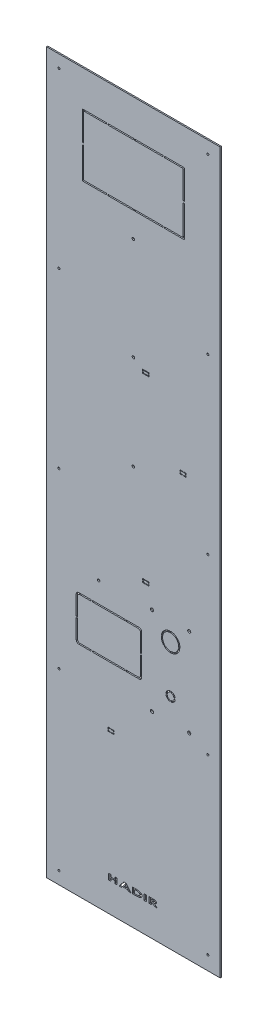
from build123d import *

# Parameters (mm, degrees)
BOSS_EXTRUDE2_DEPTH = 2
SKETCH3_R           = 2
SKETCH3_R_2         = 1.65
SKETCH3_R_3         = 2.5
SKETCH3_W           = 41.109833897
SKETCH3_H           = 2
SKETCH3_W_2         = 46.02015594
SKETCH3_W_3         = 52.483601223
CUT_EXTRUDE8_DEPTH  = 2
SKETCH4_W           = 3.627685547
SKETCH4_H           = 9.431982422
CUT_EXTRUDE9_DEPTH  = 2


with BuildPart() as part:
    # Sketch2 → Boss-Extrude2 (new body)
    with BuildSketch(Plane.XY):
        Polygon((-140, 680), (140, 680), (140, 580), (140, -480), (-140, -480), align=None)
    extrude(amount=BOSS_EXTRUDE2_DEPTH)

    # Sketch3 → Cut-Extrude8 (cut)
    with BuildSketch(Plane.XY):
        with Locations((-56.100012279, -23)):
            Circle(SKETCH3_R)
        with Locations((-120, -460)):
            Circle(SKETCH3_R_2)
        with Locations((120, -457.6)):
            Circle(SKETCH3_R_2)
        with Locations((90, -21)):
            Circle(SKETCH3_R_3)
        with Locations((89.999987721, -163)):
            Circle(SKETCH3_R_3)
        with Locations((29.999987721, -163)):
            Circle(SKETCH3_R_3)
        with Locations((29.999987721, -21)):
            Circle(SKETCH3_R_3)
        with Locations((-120, 660)):
            Circle(SKETCH3_R_2)
        with Locations((120, 660)):
            Circle(SKETCH3_R_2)
        with Locations((-120, 380.6)):
            Circle(SKETCH3_R_2)
        with Locations((120, 380.6)):
            Circle(SKETCH3_R_2)
        with Locations((120, -178.2)):
            Circle(SKETCH3_R_2)
        with Locations((-120, -178.2)):
            Circle(SKETCH3_R_2)
        with Locations((120, 101.2)):
            Circle(SKETCH3_R_2)
        with Locations((-120, 101.2)):
            Circle(SKETCH3_R_2)
        with Locations((0, 481.600002813)):
            Circle(SKETCH3_R)
        with Locations((0, 316.500002813)):
            Circle(SKETCH3_R)
        with Locations((0, 164.100002813)):
            Circle(SKETCH3_R)
        with BuildLine():
            Line((60, -36), (60.00001461, -38.000005513))
            ThreePointArc((60.00001461, -38.000005513), (64.40229458, -38.768082792), (68.284375962, -40.981554223))
            Line((68.284375962, -40.981554223), (69.558885127, -39.44026342))
            ThreePointArc((69.558885127, -39.44026342), (65.079558828, -36.88624879), (60, -36))
        make_face()
        with BuildLine():
            Line((59.000556004, -36.033342163), (59.122400034, -38.029662698))
            ThreePointArc((59.122400034, -38.029662698), (54.411111276, -39.262707552), (50.484141952, -42.142907772))
            Line((50.484141952, -42.142907772), (49.02015594, -40.780271897))
            ThreePointArc((49.02015594, -40.780271897), (53.557238864, -37.45413019), (59.000556004, -36.033342163))
        make_face()
        with BuildLine():
            Line((74.933661101, -52.409179713), (72.94252229, -52.221291353))
            ThreePointArc((72.94252229, -52.221291353), (72.168738974, -46.425929265), (68.933492433, -41.555801733))
            Line((68.933492433, -41.555801733), (70.307864595, -40.102856625))
            ThreePointArc((70.307864595, -40.102856625), (74.040835155, -45.722230337), (74.933661101, -52.409179713))
        make_face()
        with BuildLine():
            Line((74.806582661, -53.401072383), (72.832387322, -53.080932568))
            ThreePointArc((72.832387322, -53.080932568), (71.39953375, -57.249087296), (68.656303527, -60.698909196))
            Line((68.656303527, -60.698909196), (69.988033372, -62.191040241))
            ThreePointArc((69.988033372, -62.191040241), (73.153293496, -58.210477998), (74.806582661, -53.401072383))
        make_face()
        with BuildLine():
            Line((60, -66.000017478), (60.00001461, -64.000008617))
            ThreePointArc((60.00001461, -64.000008617), (64.224735631, -63.294386783), (67.990832799, -61.254121606))
            Line((67.990832799, -61.254121606), (69.220183567, -62.831670149))
            ThreePointArc((69.220183567, -62.831670149), (64.874684241, -65.185832318), (60, -66.000017478))
        make_face()
        with BuildLine():
            Line((59.000541044, -65.96712681), (59.000541044, -63.961530623))
            ThreePointArc((59.000541044, -63.961530623), (54.566773379, -62.810169218), (50.807625358, -60.192396318))
            Line((50.807625358, -60.192396318), (49.393414477, -61.606607198))
            ThreePointArc((49.393414477, -61.606607198), (53.800950165, -64.659397705), (59.000541044, -65.96712681))
        make_face()
        with BuildLine():
            Line((60.980600924, -119.564383163), (60.71910407, -121.54721432))
            ThreePointArc((60.71910407, -121.54721432), (63.889075017, -123.110912704), (65.452773401, -126.280883651))
            Line((65.452773401, -126.280883651), (67.435604557, -126.019386797))
            ThreePointArc((67.435604557, -126.019386797), (65.30328858, -121.696699141), (60.980600924, -119.564383163))
        make_face()
        with BuildLine():
            Line((58.987382691, -119.568672322), (59.257410699, -121.550359703))
            ThreePointArc((59.257410699, -121.550359703), (56.102540613, -123.119290524), (54.54720204, -126.280883651))
            Line((54.54720204, -126.280883651), (52.564370884, -126.019386797))
            ThreePointArc((52.564370884, -126.019386797), (54.685287119, -121.708123441), (58.987382691, -119.568672322))
        make_face()
        with BuildLine():
            Line((67.435604557, -127.980613203), (65.452773401, -127.719116349))
            ThreePointArc((65.452773401, -127.719116349), (63.889075017, -130.889087296), (60.71910407, -132.45278568))
            Line((60.71910407, -132.45278568), (60.980600924, -134.435616836))
            ThreePointArc((60.980600924, -134.435616836), (65.303288579, -132.303300859), (67.435604557, -127.980613203))
        make_face()
        with BuildLine():
            Line((52.564370884, -127.980613203), (54.54720204, -127.719116349))
            ThreePointArc((54.54720204, -127.719116349), (56.102540613, -130.880709476), (59.257410699, -132.449640297))
            Line((59.257410699, -132.449640297), (58.987382691, -134.431327677))
            ThreePointArc((58.987382691, -134.431327677), (54.685287119, -132.291876559), (52.564370884, -127.980613203))
        make_face()
        with BuildLine():
            Line((45.263274159, -48.201990118), (47.228183224, -48.575061007))
            ThreePointArc((47.228183224, -48.575061007), (48.212106329, -45.518651513), (49.915143539, -42.796628748))
            Line((49.915143539, -42.796628748), (48.363618413, -41.534565259))
            ThreePointArc((48.363618413, -41.534565259), (46.398572229, -44.675361768), (45.263274159, -48.201990118))
        make_face()
        with BuildLine():
            Line((45.108152373, -49.201990118), (47.093744677, -49.441726999))
            ThreePointArc((47.093744677, -49.441726999), (47.511194531, -54.609634938), (49.915144959, -59.203387129))
            Line((49.915144959, -59.203387129), (48.363618413, -60.46545222))
            ThreePointArc((48.363618413, -60.46545222), (45.589825437, -55.164965615), (45.108152373, -49.201990118))
        make_face()
        Polygon((-32.100012279, -221.1), (-35.600012279, -221.1), (-35.600012279, -220.1), (-31.100012279, -220.1), (-31.100012279, -222.5), (-32.100012279, -222.5), align=None)
        with BuildLine():
            Line((13.479987721, -60), (13.479987721, -91))
            Line((13.479987721, -91), (11.479987721, -91))
            Line((11.479987721, -91), (11.479987721, -62))
            ThreePointArc((11.479987721, -62), (10.308414845, -59.171572875), (7.479987721, -58))
            Line((7.479987721, -58), (-11.516442734, -58))
            Line((-11.516442734, -58), (-11.516442734, -56))
            Line((-11.516442734, -56), (9.479987721, -56))
            ThreePointArc((9.479987721, -56), (12.308414845, -57.171572875), (13.479987721, -60))
        make_face()
        with BuildLine():
            Line((9.479987721, -128), (-11.516442734, -128))
            Line((-11.516442734, -128), (-11.516442734, -126))
            Line((-11.516442734, -126), (7.479987721, -126))
            ThreePointArc((7.479987721, -126), (10.308414845, -124.828427125), (11.479987721, -122))
            Line((11.479987721, -122), (11.479987721, -93))
            Line((11.479987721, -93), (13.479987721, -93))
            Line((13.479987721, -93), (13.479987721, -124))
            ThreePointArc((13.479987721, -124), (12.308414845, -126.828427125), (9.479987721, -128))
        make_face()
        Polygon((24, 14.300002813), (24, 12.900002813), (25, 12.900002813), (25, 15.300002813), (20.5, 15.300002813), (20.5, 14.300002813), align=None)
        Polygon((-40.100012279, -221.1), (-40.100012279, -222.5), (-41.100012279, -222.5), (-41.100012279, -220.1), (-36.600012279, -220.1), (-36.600012279, -221.1), align=None)
        Polygon((24, 306.400002813), (24, 305.000002813), (25, 305.000002813), (25, 307.400002813), (20.5, 307.400002813), (20.5, 306.400002813), align=None)
        Polygon((84, 196.000002813), (84, 194.600002813), (85, 194.600002813), (85, 197.000002813), (80.5, 197.000002813), (80.5, 196.000002813), align=None)
        Polygon((-31.100012279, -225.9), (-35.600012279, -225.9), (-35.600012279, -224.9), (-32.100012279, -224.9), (-32.100012279, -223.5), (-31.100012279, -223.5), align=None)
        Polygon((25, 9.500002813), (20.5, 9.500002813), (20.5, 10.500002813), (24, 10.500002813), (24, 11.900002813), (25, 11.900002813), align=None)
        Polygon((15, 15.300002813), (15, 12.900002813), (16, 12.900002813), (16, 14.300002813), (19.5, 14.300002813), (19.5, 15.300002813), align=None)
        Polygon((19.5, 10.500002813), (16, 10.500002813), (16, 11.900002813), (15, 11.900002813), (15, 9.500002813), (19.5, 9.500002813), align=None)
        Polygon((-40.100012279, -223.5), (-40.100012279, -224.9), (-36.600012279, -224.9), (-36.600012279, -225.9), (-41.100012279, -225.9), (-41.100012279, -223.5), align=None)
        with BuildLine():
            Line((81.2, 622.2), (50.00515594, 622.2))
            Line((50.00515594, 622.2), (50.00515594, 620.2))
            Line((50.00515594, 620.2), (79.2, 620.2))
            ThreePointArc((79.2, 620.2), (79.907106781, 619.907106781), (80.2, 619.2))
            Line((80.2, 619.2), (80.2, 575.26))
            Line((80.2, 575.26), (82.2, 575.26))
            Line((82.2, 575.26), (82.2, 621.2))
            ThreePointArc((82.2, 621.2), (81.907106781, 621.907106781), (81.2, 622.2))
        make_face()
        with BuildLine():
            Line((81.2, 521.6), (50.00515594, 521.6))
            Line((50.00515594, 521.6), (50.00515594, 523.6))
            Line((50.00515594, 523.6), (79.2, 523.6))
            ThreePointArc((79.2, 523.6), (79.907106781, 523.892893219), (80.2, 524.6))
            Line((80.2, 524.6), (80.2, 572.28))
            Line((80.2, 572.28), (82.2, 572.28))
            Line((82.2, 572.28), (82.2, 522.6))
            ThreePointArc((82.2, 522.6), (81.907106781, 521.892893219), (81.2, 521.6))
        make_face()
        with BuildLine():
            Line((-82.2, 522.6), (-82.2, 572.28))
            Line((-82.2, 572.28), (-80.2, 572.28))
            Line((-80.2, 572.28), (-80.2, 524.6))
            ThreePointArc((-80.2, 524.6), (-79.907106781, 523.892893219), (-79.2, 523.6))
            Line((-79.2, 523.6), (-43.124833897, 523.6))
            Line((-43.124833897, 523.6), (-43.124833897, 521.6))
            Line((-43.124833897, 521.6), (-81.2, 521.6))
            ThreePointArc((-81.2, 521.6), (-81.907106781, 521.892893219), (-82.2, 522.6))
        make_face()
        with Locations((-20.569916949, 522.6)):
            Rectangle(SKETCH3_W, SKETCH3_H)
        with Locations((24.99507797, 621.2)):
            Rectangle(SKETCH3_W_2, SKETCH3_H)
        with Locations((-20.569916949, 621.2)):
            Rectangle(SKETCH3_W, SKETCH3_H)
        with Locations((24.99507797, 522.6)):
            Rectangle(SKETCH3_W_2, SKETCH3_H)
        with BuildLine():
            Line((-43.124833897, 622.2), (-43.124833897, 620.2))
            Line((-43.124833897, 620.2), (-79.2, 620.2))
            ThreePointArc((-79.2, 620.2), (-79.907106781, 619.907106781), (-80.2, 619.2))
            Line((-80.2, 619.2), (-80.2, 575.26))
            Line((-80.2, 575.26), (-82.2, 575.26))
            Line((-82.2, 575.26), (-82.2, 621.2))
            ThreePointArc((-82.2, 621.2), (-81.907106781, 621.907106781), (-81.2, 622.2))
            Line((-81.2, 622.2), (-43.124833897, 622.2))
        make_face()
        with BuildLine():
            Line((-92.120012279, -124), (-92.120012279, -93))
            Line((-92.120012279, -93), (-90.120012279, -93))
            Line((-90.120012279, -93), (-90.120012279, -122))
            ThreePointArc((-90.120012279, -122), (-88.948439404, -124.828427125), (-86.120012279, -126))
            Line((-86.120012279, -126), (-68.000043957, -126))
            Line((-68.000043957, -126), (-68.000043957, -128))
            Line((-68.000043957, -128), (-88.120012279, -128))
            ThreePointArc((-88.120012279, -128), (-90.948439404, -126.828427125), (-92.120012279, -124))
        make_face()
        with BuildLine():
            Line((-88.120012279, -56), (-68.000043957, -56))
            Line((-68.000043957, -56), (-68.000043957, -58))
            Line((-68.000043957, -58), (-86.120012279, -58))
            ThreePointArc((-86.120012279, -58), (-88.948439404, -59.171572875), (-90.120012279, -62))
            Line((-90.120012279, -62), (-90.120012279, -91))
            Line((-90.120012279, -91), (-92.120012279, -91))
            Line((-92.120012279, -91), (-92.120012279, -60))
            ThreePointArc((-92.120012279, -60), (-90.948439404, -57.171572875), (-88.120012279, -56))
        make_face()
        with Locations((-39.758243345, -57)):
            Rectangle(SKETCH3_W_3, SKETCH3_H)
        with Locations((-39.758243345, -127)):
            Rectangle(SKETCH3_W_3, SKETCH3_H)
        Polygon((25, 301.600002813), (20.5, 301.600002813), (20.5, 302.600002813), (24, 302.600002813), (24, 304.000002813), (25, 304.000002813), align=None)
        Polygon((15, 307.400002813), (15, 305.000002813), (16, 305.000002813), (16, 306.400002813), (19.5, 306.400002813), (19.5, 307.400002813), align=None)
        Polygon((85, 191.200002813), (80.5, 191.200002813), (80.5, 192.200002813), (84, 192.200002813), (84, 193.600002813), (85, 193.600002813), align=None)
        Polygon((75, 197.000002813), (75, 194.600002813), (76, 194.600002813), (76, 196.000002813), (79.5, 196.000002813), (79.5, 197.000002813), align=None)
        Polygon((19.5, 302.600002813), (16, 302.600002813), (16, 304.000002813), (15, 304.000002813), (15, 301.600002813), (19.5, 301.600002813), align=None)
        Polygon((79.5, 192.200002813), (76, 192.200002813), (76, 193.600002813), (75, 193.600002813), (75, 191.200002813), (79.5, 191.200002813), align=None)
    extrude(amount=CUT_EXTRUDE8_DEPTH, mode=Mode.SUBTRACT)

    # Sketch4 → Cut-Extrude9 (cut)
    with BuildSketch(Plane.XY):
        Polygon((-40.061027035, -423.68864967), (-36.433341488, -423.68864967), (-36.433341488, -427.316335217), (-29.6616618, -427.316335217), (-29.6616618, -423.68864967), (-26.033976253, -423.68864967), (-26.033976253, -433.120632092), (-29.6616618, -433.120632092), (-29.6616618, -429.009255138), (-36.433341488, -429.009255138), (-36.433341488, -433.120632092), (-40.061027035, -433.120632092), align=None)
        Polygon((-15.491015133, -423.68864967), (-11.785863384, -423.68864967), (-4.207401546, -433.120632092), (-8.093937572, -433.120632092), (-9.611141476, -431.185866467), (-17.667626461, -431.185866467), (-19.186719784, -433.120632092), (-23.07136639, -433.120632092), align=None)
        Polygon((-13.639383968, -426.218582455), (-16.339364513, -429.492946545), (-10.939403423, -429.492946545), align=None, mode=Mode.SUBTRACT)
        with BuildLine():
            Line((-1.486637386, -423.68864967), (2.95160915, -423.68864967))
            add(Edge.make_bspline(
                [(2.95160915, -423.68864967), (3.127327275, -423.688984823), (3.473734374, -423.689645537), (3.984515834, -423.695685686), (4.478350403, -423.704067328), (4.953790876, -423.720625979), (5.412412885, -423.736176275), (5.853899353, -423.759315101), (6.278321351, -423.786325767), (6.685408819, -423.813231538), (7.075154297, -423.848339144), (7.448276564, -423.884635264), (7.80385513, -423.929478174), (8.141659663, -423.9739191), (8.462517036, -424.022529563), (8.765710611, -424.078458407), (9.053004398, -424.133230716), (9.408853454, -424.217203151), (9.832496402, -424.331407802), (10.320683059, -424.487008028), (10.784783877, -424.666108186), (11.227457581, -424.861052742), (11.646240214, -425.079226502), (12.041481068, -425.316854837), (12.41295266, -425.57550624), (12.761699089, -425.848567784), (13.078282801, -426.138685314), (13.354690295, -426.444469014), (13.588707038, -426.762363789), (13.779621562, -427.093773412), (13.928074195, -427.437460575), (14.033953451, -427.793165455), (14.101374841, -428.160870938), (14.108705223, -428.410647325), (14.112410465, -428.536900249)],
                knots=[0, 0, 0, 0, 0.000527151, 0.001039216, 0.001532444, 0.002008818, 0.002466374, 0.002909079, 0.00333502, 0.003742233, 0.004132937, 0.004508945, 0.004866805, 0.005208037, 0.005531106, 0.005840198, 0.00613293, 0.006408377, 0.006936837, 0.007448912, 0.007944721, 0.008428546, 0.008899258, 0.009360357, 0.009811102, 0.010256384, 0.010688268, 0.011097649, 0.011491052, 0.011870238, 0.012242626, 0.01261145, 0.012981723, 0.013360179, 0.013360179, 0.013360179, 0.013360179], degree=3))
            add(Edge.make_bspline(
                [(14.112410465, -428.536900249), (14.110484441, -428.627098675), (14.106670519, -428.805709991), (14.068368459, -429.070447547), (14.01094765, -429.330126093), (13.926475466, -429.583856009), (13.820895386, -429.832895641), (13.688582279, -430.075084434), (13.536383202, -430.313918356), (13.357640248, -430.543805465), (13.158773745, -430.765946054), (12.944145359, -430.981660126), (12.710273523, -431.18637538), (12.458359384, -431.381074155), (12.188485584, -431.566142684), (11.899297101, -431.739806402), (11.594237531, -431.906411793), (11.160697439, -432.112544177), (10.593854146, -432.343941389), (9.88567113, -432.57700142), (9.149332163, -432.761814491), (8.579370263, -432.864239729), (8.18305888, -432.919922558), (7.962672228, -432.946711485), (7.723694997, -432.968078666), (7.467474215, -432.991456007), (7.193458078, -433.011899786), (6.902471813, -433.030730287), (6.593858222, -433.047893384), (6.266914688, -433.062122184), (5.92187515, -433.078518856), (5.559031842, -433.088808208), (5.178635285, -433.098718654), (4.780563246, -433.105247047), (4.364929275, -433.114380819), (3.931583196, -433.116357075), (3.480657457, -433.121767599), (3.173932727, -433.121015225), (3.017738834, -433.120632092)],
                knots=[0, 0, 0, 0, 0.000270425, 0.000535496, 0.000800891, 0.001067373, 0.001336554, 0.0016113, 0.001894316, 0.002185311, 0.00248375, 0.002788363, 0.003097633, 0.003415472, 0.003743018, 0.004078718, 0.004427049, 0.004785366, 0.00551833, 0.006262207, 0.007020156, 0.007793984, 0.007998128, 0.008220768, 0.008459912, 0.008717871, 0.008992624, 0.009284207, 0.009592652, 0.009919871, 0.010265965, 0.010628911, 0.011008801, 0.01140754, 0.011823281, 0.012255975, 0.012707562, 0.013176138, 0.013176138, 0.013176138, 0.013176138], degree=3))
            Line((3.017738834, -433.120632092), (-1.486637386, -433.120632092))
            Line((-1.486637386, -433.120632092), (-1.486637386, -423.68864967))
        make_face()
        with BuildLine():
            Line((2.141048161, -425.381569592), (2.141048161, -431.42771217))
            Line((2.141048161, -431.42771217), (3.934107319, -431.42771217))
            add(Edge.make_bspline(
                [(3.934107319, -431.42771217), (4.146998468, -431.427503063), (4.55772495, -431.427099638), (5.150970696, -431.409565982), (5.699832088, -431.391723109), (6.202391293, -431.358279757), (6.660193029, -431.321072779), (7.071211746, -431.268296371), (7.438911053, -431.21488409), (7.765171715, -431.145052283), (8.062884447, -431.066400653), (8.341503841, -430.975771473), (8.607161326, -430.874589528), (8.857394385, -430.757810165), (9.09532529, -430.632351579), (9.319648148, -430.493792486), (9.529971516, -430.342329842), (9.725290704, -430.179016328), (9.90432306, -430.005892076), (10.059146754, -429.820748384), (10.191202686, -429.626014684), (10.300213506, -429.422067721), (10.380436068, -429.205919391), (10.442319526, -428.981868164), (10.478664669, -428.747184883), (10.482690582, -428.587406984), (10.484724918, -428.506669537)],
                knots=[0, 0, 0, 0, 0.000638635, 0.001232105, 0.001780431, 0.002285927, 0.002743003, 0.003158044, 0.003528948, 0.003857272, 0.004158378, 0.004452352, 0.004735865, 0.005010612, 0.005280243, 0.00554241, 0.005800929, 0.006057118, 0.006305633, 0.006547065, 0.00677974, 0.007010473, 0.007238913, 0.007469918, 0.00770694, 0.007949051, 0.007949051, 0.007949051, 0.007949051], degree=3))
            add(Edge.make_bspline(
                [(10.484724918, -428.506669537), (10.483162085, -428.4436347), (10.480090322, -428.319739135), (10.459032776, -428.136374978), (10.422989635, -427.958929616), (10.373280771, -427.786008048), (10.312002089, -427.617758209), (10.233094203, -427.455735831), (10.140412821, -427.299355736), (10.034967394, -427.147814744), (9.913482642, -427.003199871), (9.780789134, -426.861287444), (9.630334181, -426.727652105), (9.466985972, -426.599174986), (9.291235272, -426.473642042), (9.100058307, -426.355540875), (8.895597455, -426.241093396), (8.751905731, -426.17243877), (8.678439823, -426.137337414)],
                knots=[0, 0, 0, 0, 0.000189093, 0.000371664, 0.000552861, 0.000731679, 0.000911024, 0.001089332, 0.001271443, 0.001455949, 0.001642467, 0.001837599, 0.002038287, 0.002245435, 0.002460903, 0.002685816, 0.002919249, 0.003163452, 0.003163452, 0.003163452, 0.003163452], degree=3))
            add(Edge.make_bspline(
                [(8.678439823, -426.137337414), (8.608120409, -426.10658828), (8.4636369, -426.043408817), (8.237146977, -425.956333197), (7.994603018, -425.877699001), (7.737475128, -425.804000384), (7.464583061, -425.736101773), (7.17673991, -425.673650497), (6.872627983, -425.620014631), (6.554241401, -425.567708302), (6.219307042, -425.526126542), (5.869387448, -425.484831668), (5.503816969, -425.4540879), (5.122765179, -425.427224308), (4.726537323, -425.406933574), (4.314625679, -425.391145077), (3.88752041, -425.384727301), (3.597791205, -425.382634253), (3.450415913, -425.381569592)],
                knots=[0, 0, 0, 0, 0.00023023, 0.000473048, 0.00072758, 0.000994898, 0.001275348, 0.001571077, 0.00187831, 0.002201671, 0.00253891, 0.002890697, 0.003258649, 0.003639343, 0.004036665, 0.004448836, 0.004875911, 0.005318052, 0.005318052, 0.005318052, 0.005318052], degree=3))
            Line((3.450415913, -425.381569592), (2.141048161, -425.381569592))
        make_face(mode=Mode.SUBTRACT)
        with Locations((18.949324528, -428.404640881)):
            Rectangle(SKETCH4_W, SKETCH4_H)
        with BuildLine():
            Line((25.479158512, -423.68864967), (29.465833775, -423.68864967))
            add(Edge.make_bspline(
                [(29.465833775, -423.68864967), (29.599981747, -423.689364143), (29.863239385, -423.690766256), (30.250595035, -423.691389972), (30.622806042, -423.697815745), (30.980548006, -423.705089853), (31.323160558, -423.714743859), (31.651372201, -423.725102256), (31.96489456, -423.741771258), (32.264223846, -423.755147652), (32.548204916, -423.774875546), (32.817157845, -423.795469182), (33.071632762, -423.818007273), (33.311625483, -423.842445631), (33.537122555, -423.868927877), (33.747541168, -423.896995872), (33.943672138, -423.926699181), (34.181933284, -423.972240094), (34.463783083, -424.032958731), (34.786177735, -424.117297658), (35.091373182, -424.213832883), (35.379166008, -424.32123663), (35.650251427, -424.440804676), (35.905270256, -424.57006067), (36.142402321, -424.712499419), (36.361349169, -424.864655794), (36.5588835, -425.025902521), (36.73349202, -425.194347525), (36.878992173, -425.372516519), (36.999968932, -425.556896556), (37.093615603, -425.749241346), (37.159722433, -425.948734603), (37.201464863, -426.155760237), (37.206248882, -426.296480053), (37.208675114, -426.3678466)],
                knots=[0, 0, 0, 0, 0.000402451, 0.000789786, 0.001162045, 0.001519225, 0.00186323, 0.002190296, 0.002504303, 0.002805101, 0.003089143, 0.003358245, 0.003614322, 0.003855532, 0.004081924, 0.004295428, 0.004492372, 0.004676917, 0.005023058, 0.005357149, 0.005676242, 0.005982963, 0.006278209, 0.006564666, 0.006840094, 0.007107412, 0.007363852, 0.00760435, 0.007833936, 0.008052473, 0.008264576, 0.008473697, 0.008681576, 0.00889549, 0.00889549, 0.00889549, 0.00889549], degree=3))
            add(Edge.make_bspline(
                [(37.208675114, -426.3678466), (37.205735808, -426.442387543), (37.199930607, -426.589607703), (37.154675509, -426.805083861), (37.082971794, -427.011603557), (36.978794816, -427.208239558), (36.846026775, -427.394964751), (36.684499814, -427.57256761), (36.495164297, -427.741337298), (36.273374051, -427.896818652), (36.025783344, -428.047515026), (35.746070933, -428.183265045), (35.43989505, -428.315090123), (35.101864226, -428.432254999), (34.735855747, -428.543878059), (34.339847151, -428.645391881), (33.915062122, -428.738030445), (33.620868067, -428.789866306), (33.469513813, -428.816534344)],
                knots=[0, 0, 0, 0, 0.000223463, 0.000441345, 0.000657665, 0.000877399, 0.001106487, 0.001343268, 0.001596204, 0.001865703, 0.002154741, 0.002464847, 0.002797541, 0.003154301, 0.003537425, 0.003945281, 0.004380365, 0.004841383, 0.004841383, 0.004841383, 0.004841383], degree=3))
            Line((33.469513813, -428.816534344), (38.1155965, -433.120632092))
            Line((38.1155965, -433.120632092), (34.030671421, -433.120632092))
            Line((34.030671421, -433.120632092), (29.592424885, -429.009255138))
            Line((29.592424885, -429.009255138), (29.106844059, -429.009255138))
            Line((29.106844059, -429.009255138), (29.106844059, -433.120632092))
            Line((29.106844059, -433.120632092), (25.479158512, -433.120632092))
            Line((25.479158512, -433.120632092), (25.479158512, -423.68864967))
        make_face()
        with BuildLine():
            Line((29.106844059, -427.316335217), (30.325519672, -427.316335217))
            add(Edge.make_bspline(
                [(30.325519672, -427.316335217), (30.474155201, -427.315417541), (30.759491203, -427.313655876), (31.169665442, -427.305688745), (31.543807664, -427.286095112), (31.881470279, -427.261871781), (32.183700284, -427.233394146), (32.448900623, -427.193349358), (32.679001939, -427.149635517), (32.874825984, -427.096426327), (33.042086483, -427.035921589), (33.185426688, -426.966638264), (33.306176773, -426.885855169), (33.408184393, -426.79852123), (33.485260756, -426.697497324), (33.541121486, -426.588948134), (33.574636243, -426.469926857), (33.578829583, -426.387586814), (33.580989567, -426.345173565)],
                knots=[0, 0, 0, 0, 0.000445919, 0.000856032, 0.001230614, 0.001569711, 0.001871646, 0.002140992, 0.002374066, 0.002573916, 0.002749062, 0.002907075, 0.003050135, 0.003183977, 0.003307933, 0.003428767, 0.003548413, 0.003675511, 0.003675511, 0.003675511, 0.003675511], degree=3))
            add(Edge.make_bspline(
                [(33.580989567, -426.345173565), (33.577280321, -426.294633128), (33.569764288, -426.192223201), (33.496710639, -426.04858207), (33.384722547, -425.916647156), (33.229746774, -425.80089608), (33.042098335, -425.695780012), (32.823270587, -425.605303252), (32.574790554, -425.5329912), (32.345280154, -425.485814998), (32.135279115, -425.4570355), (31.944439971, -425.436028935), (31.723793119, -425.42030018), (31.472549203, -425.404427068), (31.190939764, -425.393847533), (30.878529029, -425.386243537), (30.536510616, -425.383093036), (30.298438084, -425.382091529), (30.174366108, -425.381569592)],
                knots=[0, 0, 0, 0, 0.000150704, 0.000305371, 0.000473019, 0.000666904, 0.000881808, 0.001117259, 0.001375509, 0.001657127, 0.001819321, 0.00201128, 0.002232995, 0.002482856, 0.002766496, 0.003078342, 0.003420348, 0.003792568, 0.003792568, 0.003792568, 0.003792568], degree=3))
            Line((30.174366108, -425.381569592), (29.106844059, -425.381569592))
            Line((29.106844059, -425.381569592), (29.106844059, -427.316335217))
        make_face(mode=Mode.SUBTRACT)
    extrude(amount=CUT_EXTRUDE9_DEPTH, mode=Mode.SUBTRACT)


solid = part.part
